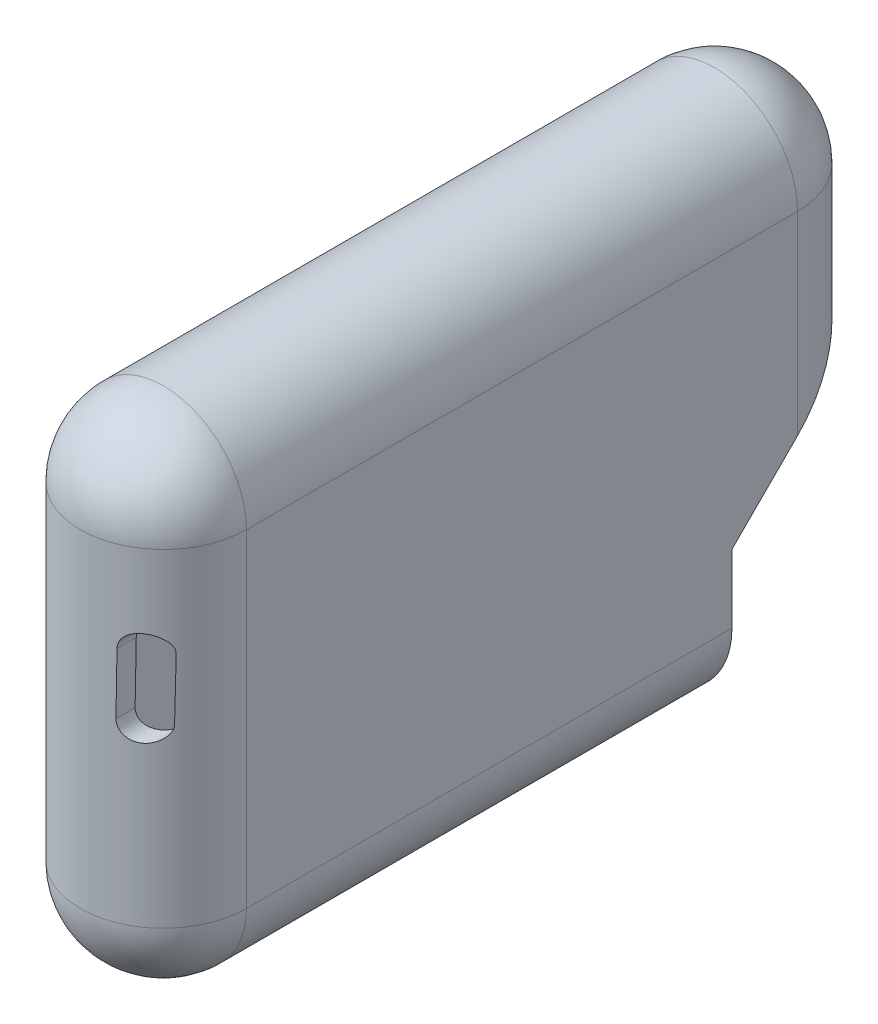
from build123d import *

# Parameters (mm, degrees)
EXTRUDE_THIN1_DEPTH      = 8
EXTRUDE_THIN1_DEPTH_BACK = 55
REVOLVE1_ANGLE           = 180
CUT_EXTRUDE1_DEPTH       = 1
CUT_EXTRUDE1_DEPTH_BACK  = 73.5
REVOLVE2_ANGLE           = 180
CUT_EXTRUDE2_DEPTH       = 1.0000001
CUT_EXTRUDE2_DEPTH_BACK  = 20.0000001


with BuildPart() as part:
    # Sketch1 → Extrude-Thin1 (new body, two sides)
    with BuildSketch(Plane.XY) as extrude_thin1_sk:
        with BuildLine():
            Line((-10.608745061, -19.461766721), (-10.608745061, 18.038233279))
            ThreePointArc((-10.608745061, 18.038233279), (-1.108745061, 27.538233279), (8.391254939, 18.038233279))
            Line((8.391254939, 18.038233279), (8.391254939, -19.461766721))
            ThreePointArc((8.391254939, -19.461766721), (-1.108745061, -28.961766721), (-10.608745061, -19.461766721))
        make_face()
        with BuildLine():
            Line((-8.608745061, -19.461766721), (-8.608745061, 18.038233279))
            ThreePointArc((-8.608745061, 18.038233279), (-1.108745061, 25.538233279), (6.391254939, 18.038233279))
            Line((6.391254939, 18.038233279), (6.391254939, -19.461766721))
            ThreePointArc((6.391254939, -19.461766721), (-1.108745061, -26.961766721), (-8.608745061, -19.461766721))
        make_face(mode=Mode.SUBTRACT)
    extrude(amount=EXTRUDE_THIN1_DEPTH)
    extrude(extrude_thin1_sk.sketch, amount=-EXTRUDE_THIN1_DEPTH_BACK)

    # Sketch3 → Revolve1 (revolve)
    with BuildSketch(Plane.XY.offset(8)):
        with BuildLine():
            Line((6.391254939, -19.461766721), (6.391254939, 18.038233279))
            ThreePointArc((6.391254939, 18.038233279), (4.194555798, 23.341534137), (-1.108745061, 25.538233279))
            Line((-1.108745061, 25.538233279), (-1.108745061, 27.538233279))
            ThreePointArc((-1.108745061, 27.538233279), (5.608769361, 24.7557477), (8.391254939, 18.038233279))
            Line((8.391254939, 18.038233279), (8.391254939, -19.461766721))
            ThreePointArc((8.391254939, -19.461766721), (5.608769361, -26.179281143), (-1.108745061, -28.961766721))
            Line((-1.108745061, -28.961766721), (-1.108745061, -26.961766721))
            ThreePointArc((-1.108745061, -26.961766721), (4.194555798, -24.76506758), (6.391254939, -19.461766721))
        make_face()
    revolve(axis=Axis((-1.108745061, 27.538233279, 8), (0, -1, 0)), revolution_arc=REVOLVE1_ANGLE)

    # Sketch4 → Cut-Extrude1 (cut, two sides)
    with BuildSketch(Plane(origin=(-1.108745061, -19.461766721, 17.5), x_dir=(1, 0, 0), z_dir=(0, 0, 1))) as cut_extrude1_sk:
        with BuildLine():
            Line((7.413248602, 27.101186929), (7.328248101, 20.145490054))
            ThreePointArc((7.328248101, 20.145490054), (5.359735954, 18.224508573), (3.438754472, 20.19302072))
            Line((3.438754472, 20.19302072), (3.523754973, 27.148717596))
            ThreePointArc((3.523754973, 27.148717596), (5.492267121, 29.069699077), (7.413248602, 27.101186929))
        make_face()
    extrude(amount=CUT_EXTRUDE1_DEPTH, mode=Mode.SUBTRACT)
    extrude(cut_extrude1_sk.sketch, amount=-CUT_EXTRUDE1_DEPTH_BACK, mode=Mode.SUBTRACT)

    # Sketch5 → Revolve2 (revolve)
    with BuildSketch(Plane(origin=(0, 0, -55), x_dir=(-1, 0, 0), z_dir=(0, 0, -1))):
        with BuildLine():
            Line((-6.391254939, -19.461766721), (-6.391254939, 18.038233279))
            ThreePointArc((-6.391254939, 18.038233279), (-4.194555798, 23.341534137), (1.108745061, 25.538233279))
            Line((1.108745061, 25.538233279), (1.108745061, 27.538233279))
            ThreePointArc((1.108745061, 27.538233279), (-5.608769361, 24.7557477), (-8.391254939, 18.038233279))
            Line((-8.391254939, 18.038233279), (-8.391254939, -19.461766721))
            ThreePointArc((-8.391254939, -19.461766721), (-5.608769361, -26.179281143), (1.108745061, -28.961766721))
            Line((1.108745061, -28.961766721), (1.108745061, -26.961766721))
            ThreePointArc((1.108745061, -26.961766721), (-4.194555798, -24.76506758), (-6.391254939, -19.461766721))
        make_face()
    revolve(axis=Axis((-1.108745061, -28.961766721, -55), (0, 1, 0)), revolution_arc=REVOLVE2_ANGLE)

    # Sketch6 → Cut-Extrude2 (cut, two sides)
    with BuildSketch(Plane(origin=(8.391254939, 0, 0), x_dir=(0, 0, -1), z_dir=(1, 0, 0))) as cut_extrude2_sk:
        Polygon((47.502612286, -35.061794905), (47.502612286, -11.65288681), (66.549267121, 7.393768025), (66.549267121, -35.061794905), align=None)
    extrude(amount=CUT_EXTRUDE2_DEPTH, mode=Mode.SUBTRACT)
    extrude(cut_extrude2_sk.sketch, amount=-CUT_EXTRUDE2_DEPTH_BACK, mode=Mode.SUBTRACT)


solid = part.part
